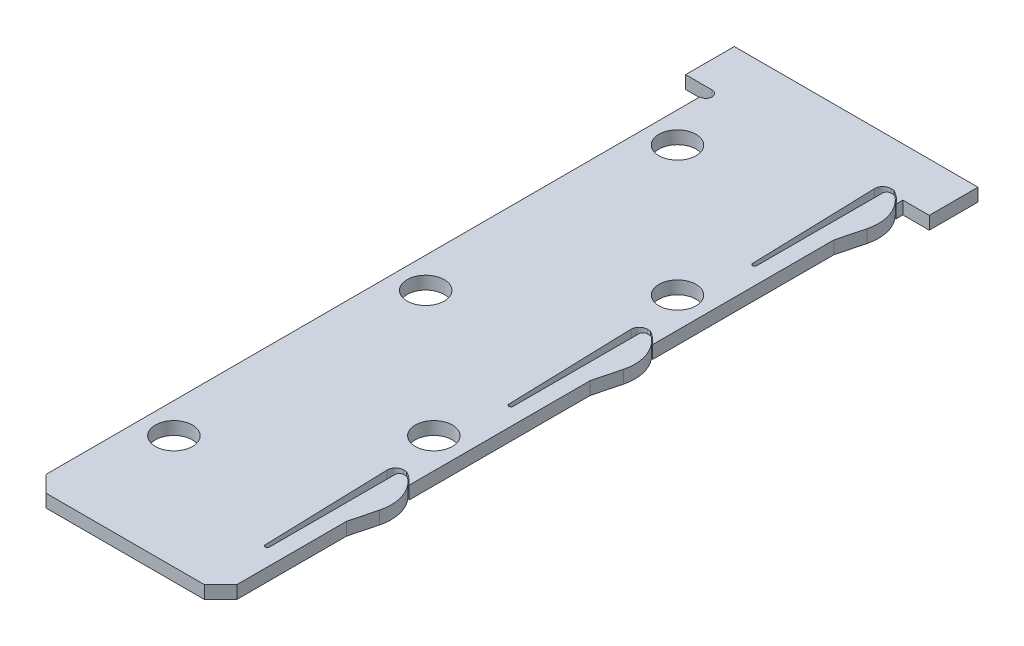
from build123d import *

# Parameters (mm, degrees)
SKETCH1_W           = 23.5
SKETCH1_H           = 90
BOSS_EXTRUDE1_DEPTH = 1.5875
BOSS_EXTRUDE2_DEPTH = 1.5875
CUT_EXTRUDE3_DEPTH  = 2.5875
LPATTERN1_COUNT     = 3
LPATTERN1_PITCH     = 30
SKETCH5_R           = 2.286
CUT_EXTRUDE4_DEPTH  = 2.5875
CHAMFER1_SIZE       = 2
SKETCH6_W           = 3.25
SKETCH6_H           = 6
BOSS_EXTRUDE3_DEPTH = 1.5875
FILLET1_R           = 1
FILLET2_R           = 0.5
SKETCH7_R           = 0.75
CUT_EXTRUDE5_DEPTH  = 2.5875


with BuildPart() as part:
    # Sketch1 → Boss-Extrude1 (new body)
    with BuildSketch(Plane(origin=(0, 0, 0), x_dir=(1, 0, 0), z_dir=(0, 1, 0))):
        Rectangle(SKETCH1_W, SKETCH1_H)
    extrude(amount=BOSS_EXTRUDE1_DEPTH)

    # Sketch2 → Boss-Extrude2 (add)
    with BuildSketch(Plane(origin=(0, 1.5875, 0), x_dir=(1, 0, 0), z_dir=(0, 1, 0))):
        with BuildLine():
            Line((11.75, -29.5), (12.590477082, -26.25290926))
            ThreePointArc((12.590477082, -26.25290926), (3.882734587, -21.830732226), (9.929449472, -29.5))
            Line((9.929449472, -29.5), (11.75, -29.5))
        make_face()
    boss_extrude2 = extrude(amount=-BOSS_EXTRUDE2_DEPTH)

    # Sketch4 → Cut-Extrude3 (cut, through all)
    with BuildSketch(Plane(origin=(0, 1.5875, 0), x_dir=(1, 0, 0), z_dir=(0, 1, 0))):
        with BuildLine():
            Line((10.75, -21), (9.75, -21))
            Line((9.75, -21), (9.75, -37))
            ThreePointArc((9.75, -37), (9.503785707, -37.249971335), (9.250114653, -37.007570546))
            Line((9.250114653, -37.007570546), (8.75, -20.5))
            Line((8.75, -20.5), (10.15, -20.5))
            ThreePointArc((10.15, -20.5), (11.018993513, -21.085452592), (11.75, -21.836141596))
            Line((11.75, -21.836141596), (11.75, -22))
            ThreePointArc((11.75, -22), (11.285533906, -21.464466094), (10.75, -21))
        make_face()
    cut_extrude3 = extrude(amount=-CUT_EXTRUDE3_DEPTH, mode=Mode.SUBTRACT)

    # LPattern1: Boss-Extrude2, Cut-Extrude3 ×3
    with Locations(*[(0, 0, -i * LPATTERN1_PITCH) for i in range(1, LPATTERN1_COUNT)]):
        add(boss_extrude2)
        add(cut_extrude3, mode=Mode.SUBTRACT)

    # Sketch5 → Cut-Extrude4 (cut, through all)
    with BuildSketch(Plane(origin=(0, 1.5875, 0), x_dir=(1, 0, 0), z_dir=(0, 1, 0))):
        with Locations((-8, -31)):
            Circle(SKETCH5_R)
        with Locations((8, -15)):
            Circle(SKETCH5_R)
        with Locations((-8, 31)):
            Circle(SKETCH5_R)
        with Locations((8, 15)):
            Circle(SKETCH5_R)
        with Locations((-8, 0)):
            Circle(SKETCH5_R)
    extrude(amount=-CUT_EXTRUDE4_DEPTH, mode=Mode.SUBTRACT)

    # Chamfer1
    chamfer1_edges = [part.edges().sort_by_distance(p)[0] for p in [
        (11.75, 0.79375, 45),
        (-11.75, 0.79375, 45),
    ]]
    chamfer(chamfer1_edges, length=CHAMFER1_SIZE)

    # Sketch6 → Boss-Extrude3 (add)
    with BuildSketch(Plane(origin=(0, 1.5875, 0), x_dir=(1, 0, 0), z_dir=(0, 1, 0))):
        with Locations((-13.375, 42)):
            Rectangle(SKETCH6_W, SKETCH6_H)
        with Locations((13.375, 42)):
            Rectangle(SKETCH6_W, SKETCH6_H)
    extrude(amount=-BOSS_EXTRUDE3_DEPTH)

    # Fillet1
    fillet1_edges = [part.edges().sort_by_distance(p)[0] for p in [
        (8.75, 0.79375, -39.5),
        (8.75, 0.79375, 20.5),
        (8.75, 0.79375, -9.5),
    ]]
    fillet(fillet1_edges, radius=FILLET1_R)

    # Fillet2
    fillet2_edges = [part.edges().sort_by_distance(p)[0] for p in [
        (9.75, 0.79375, -39),
        (9.75, 0.79375, 21),
        (9.75, 0.79375, -9),
    ]]
    fillet(fillet2_edges, radius=FILLET2_R)

    # Sketch7 → Cut-Extrude5 (cut, through all)
    with BuildSketch(Plane(origin=(0, 1.5875, 0), x_dir=(1, 0, 0), z_dir=(0, 1, 0))):
        with Locations((-11.75, 38.25)):
            Circle(SKETCH7_R)
    extrude(amount=-CUT_EXTRUDE5_DEPTH, mode=Mode.SUBTRACT)


solid = part.part
